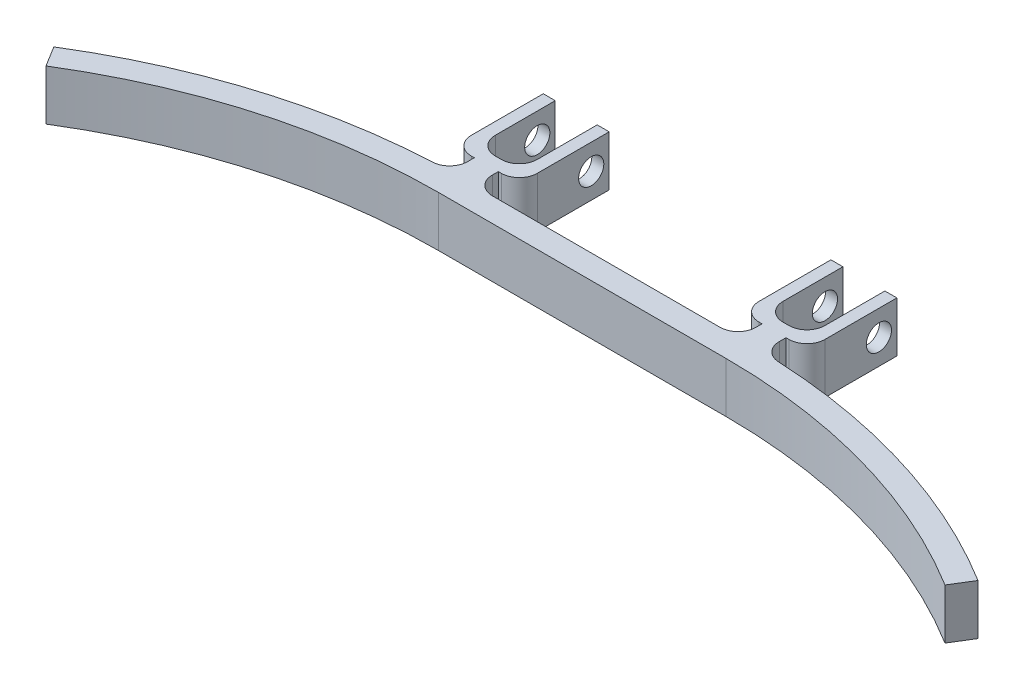
from build123d import *

# Parameters (mm, degrees)
BOSS_EXTRUDE1_DEPTH  = 4.2
FILLET2_R            = 3
FILLET5_R            = 3
SKETCH3_R            = 2.1
CUT_EXTRUDE1_DEPTH   = 16
FILLET6_R            = 3
FILLET2_OF_MIRROR1_R = 3
FILLET5_OF_MIRROR1_R = 3
FILLET6_OF_MIRROR1_R = 3


with BuildPart() as part:
    # Sketch2 → Boss-Extrude1 (new, symmetric)
    with BuildSketch(Plane(origin=(0, 0, 0), x_dir=(1, 0, 0), z_dir=(0, 1, 0))):
        with BuildLine():
            Line((0, 0), (-24, 0))
            ThreePointArc((-24, 0), (-50.506230897, -3.686965816), (-75, -14.467933694))
            Line((-75, -14.467933694), (-77.100442165, -11.063797576))
            ThreePointArc((-77.100442165, -11.063797576), (-52.558629139, -0.11650046), (-26, 3.980220055))
            Line((-26, 3.980220055), (-26, 8))
            Line((-26, 8), (-29.5, 8))
            Line((-29.5, 8), (-29.5, 23))
            Line((-29.5, 23), (-27.5, 23))
            Line((-27.5, 23), (-27.5, 10))
            Line((-27.5, 10), (-24, 10))
            Line((-24, 10), (-20.5, 10))
            Line((-20.5, 10), (-20.5, 23))
            Line((-20.5, 23), (-18.5, 23))
            Line((-18.5, 23), (-18.5, 8))
            Line((-18.5, 8), (-22, 8))
            Line((-22, 8), (-22, 4))
            Line((-22, 4), (0, 4))
            Line((0, 4), (0, 0))
        make_face()
    boss_extrude1 = extrude(amount=BOSS_EXTRUDE1_DEPTH, both=True)

    # Fillet2
    fillet2_edges = [part.edges().sort_by_distance(p)[0] for p in [
        (-29.5, 0, -8),
    ]]
    fillet(fillet2_edges, radius=FILLET2_R)

    # Fillet5
    fillet5_edges = [part.edges().sort_by_distance(p)[0] for p in [
        (-26, 0, -3.980220055),
        (-22, 0, -4),
        (-18.5, 0, -8),
    ]]
    fillet(fillet5_edges, radius=FILLET5_R)

    # Sketch3 → Cut-Extrude1 (cut)
    with BuildSketch(Plane(origin=(-18.5, 0, 0), x_dir=(0, 0, -1), z_dir=(1, 0, 0))):
        with Locations((20, 0)):
            Circle(SKETCH3_R)
    cut_extrude1 = extrude(amount=-CUT_EXTRUDE1_DEPTH, mode=Mode.SUBTRACT)

    # Fillet6
    fillet6_edges = [part.edges().sort_by_distance(p)[0] for p in [
        (-20.5, 0, -10),
        (-27.5, 0, -10),
    ]]
    fillet(fillet6_edges, radius=FILLET6_R)

    # Mirror1: Boss-Extrude1, Cut-Extrude1 across plane
    add(boss_extrude1.mirror(Plane(origin=(0, -4.2, -4), x_dir=(0, 0, 1), z_dir=(1, 0, 0))))
    add(cut_extrude1.mirror(Plane(origin=(0, -4.2, -4), x_dir=(0, 0, 1), z_dir=(1, 0, 0))), mode=Mode.SUBTRACT)

    # Fillet2 of Mirror1
    fillet2_of_mirror1_edges = [part.edges().sort_by_distance(p)[0] for p in [
        (29.5, 0, -8),
    ]]
    fillet(fillet2_of_mirror1_edges, radius=FILLET2_OF_MIRROR1_R)

    # Fillet5 of Mirror1
    fillet5_of_mirror1_edges = [part.edges().sort_by_distance(p)[0] for p in [
        (26, 0, -3.980220055),
        (22, 0, -4),
        (18.5, 0, -8),
    ]]
    fillet(fillet5_of_mirror1_edges, radius=FILLET5_OF_MIRROR1_R)

    # Fillet6 of Mirror1
    fillet6_of_mirror1_edges = [part.edges().sort_by_distance(p)[0] for p in [
        (20.5, 0, -10),
        (27.5, 0, -10),
    ]]
    fillet(fillet6_of_mirror1_edges, radius=FILLET6_OF_MIRROR1_R)


solid = part.part
